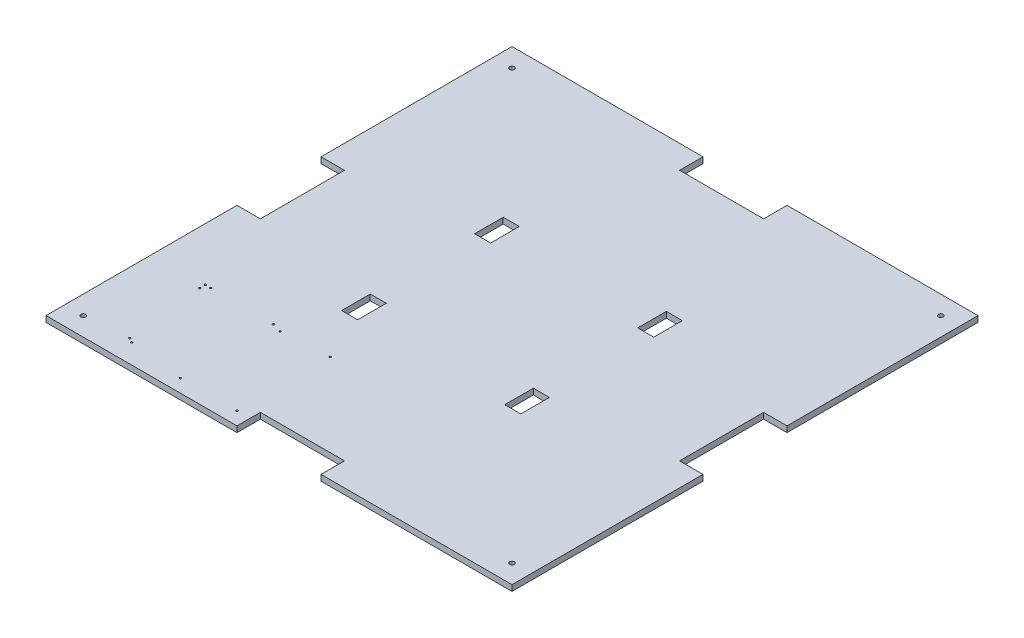
from build123d import *

# Parameters (mm, degrees)
SKETCH2_W           = 250
SKETCH2_H           = 250
BOSS_EXTRUDE1_DEPTH = 3.175
SKETCH3_W           = 8.6
SKETCH3_H           = 15.35
CUT_EXTRUDE1_DEPTH  = 10
SKETCH4_W           = 45.1
SKETCH4_H           = 25.1
SKETCH4_W_2         = 25.1
SKETCH4_H_2         = 45.1
CUT_EXTRUDE2_DEPTH  = 10
M3_TAPPED_HOLE1_D   = 2.5
M3_TAPPED_HOLE2_D   = 2.5
SKETCH9_R           = 0.5
CUT_EXTRUDE3_DEPTH  = 4.175


with BuildPart() as part:
    # Sketch2 → Boss-Extrude1 (new body)
    with BuildSketch(Plane(origin=(0, 0, 0), x_dir=(1, 0, 0), z_dir=(0, 1, 0))):
        Rectangle(SKETCH2_W, SKETCH2_H)
    extrude(amount=BOSS_EXTRUDE1_DEPTH)

    # Sketch3 → Cut-Extrude1 (cut)
    with BuildSketch(Plane(origin=(0, 3.175, 0), x_dir=(1, 0, 0), z_dir=(0, 1, 0))):
        with Locations((-43.75, 35.675)):
            Rectangle(SKETCH3_W, SKETCH3_H)
        with Locations((-43.75, -35.675)):
            Rectangle(SKETCH3_W, SKETCH3_H)
        with Locations((43.75, -35.675)):
            Rectangle(SKETCH3_W, SKETCH3_H)
        with Locations((43.75, 35.675)):
            Rectangle(SKETCH3_W, SKETCH3_H)
    extrude(amount=-CUT_EXTRUDE1_DEPTH, mode=Mode.SUBTRACT)

    # Sketch4 → Cut-Extrude2 (cut)
    with BuildSketch(Plane(origin=(0, 3.175, 0), x_dir=(1, 0, 0), z_dir=(0, 1, 0))):
        with Locations((0, 125)):
            Rectangle(SKETCH4_W, SKETCH4_H)
        with Locations((125, 0)):
            Rectangle(SKETCH4_W_2, SKETCH4_H_2)
        with Locations((0, -125)):
            Rectangle(SKETCH4_W, SKETCH4_H)
        with Locations((-125, 0)):
            Rectangle(SKETCH4_W_2, SKETCH4_H_2)
    extrude(amount=-CUT_EXTRUDE2_DEPTH, mode=Mode.SUBTRACT)

    # M3 Tapped Hole1 (through all)
    with Locations(Plane(origin=(0, 3.175, 0), x_dir=(1, 0, 0), z_dir=(0, 1, 0))):
        with Locations((-115, 115)):
            Hole(M3_TAPPED_HOLE1_D / 2)

    # M3 Tapped Hole2 (through all)
    with Locations(Plane(origin=(0, 3.175, 0), x_dir=(1, 0, 0), z_dir=(0, 1, 0))):
        with Locations((115, 115), (115, -115), (-115, -115)):
            Hole(M3_TAPPED_HOLE2_D / 2)

    # Sketch9 → Cut-Extrude3 (cut, through all)
    with BuildSketch(Plane(origin=(0, 3.175, 0), x_dir=(1, 0, 0), z_dir=(0, 1, 0))):
        with Locations((-92.05, -113)):
            Circle(SKETCH9_R)
        with Locations((-89.55, -114.5)):
            Circle(SKETCH9_R)
        with Locations((-59.95, -118)):
            Circle(SKETCH9_R)
        with Locations((-29.55, -118)):
            Circle(SKETCH9_R)
        with Locations((-29.55, -68)):
            Circle(SKETCH9_R)
        with Locations((-54.85, -69.6)):
            Circle(SKETCH9_R)
        with Locations((-59.95, -68)):
            Circle(SKETCH9_R)
        with Locations((-96.55, -68)):
            Circle(SKETCH9_R)
        with Locations((-93.65, -68)):
            Circle(SKETCH9_R)
        with Locations((-96.55, -71)):
            Circle(SKETCH9_R)
    extrude(amount=-CUT_EXTRUDE3_DEPTH, mode=Mode.SUBTRACT)


solid = part.part
